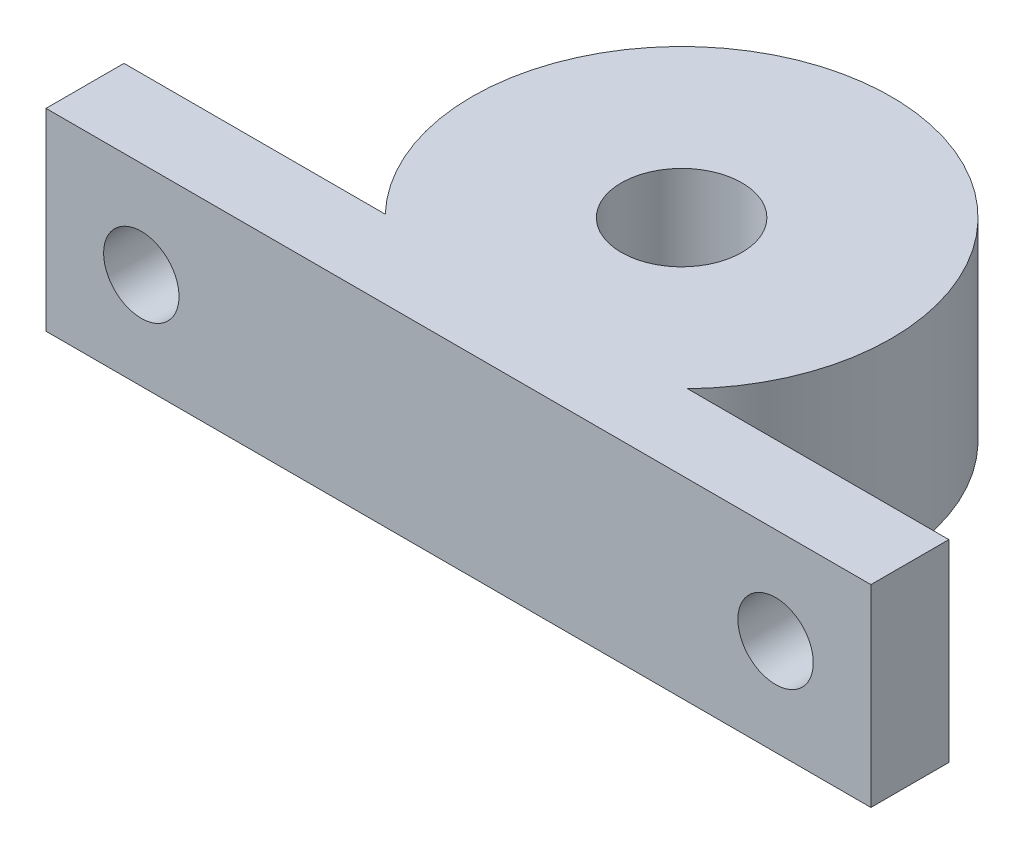
from build123d import *

# Parameters (mm, degrees)
SKETCH1_R           = 4
BOSS_EXTRUDE1_DEPTH = 12.8
SKETCH2_R           = 2.5
CUT_EXTRUDE1_DEPTH  = 6.17


with BuildPart() as part:
    # Sketch1 → Boss-Extrude1 (new body)
    with BuildSketch(Plane(origin=(0, 0, 0), x_dir=(1, 0, 0), z_dir=(0, 1, 0))):
        with BuildLine():
            Line((0, 0), (54.7, 0))
            Line((54.7, 0), (54.7, 5.17))
            Line((54.7, 5.17), (37.373627088, 5.17))
            ThreePointArc((37.373627088, 5.17), (27.35, 28.7), (17.326372912, 5.17))
            Line((17.326372912, 5.17), (0, 5.17))
            Line((0, 5.17), (0, 0))
        make_face()
        with Locations((27.35, 14.8)):
            Circle(SKETCH1_R, mode=Mode.SUBTRACT)
    extrude(amount=BOSS_EXTRUDE1_DEPTH)

    # Sketch2 → Cut-Extrude1 (cut, through all)
    with BuildSketch(Plane(origin=(0, 0, -5.17), x_dir=(-1, 0, 0), z_dir=(0, 0, -1))):
        with Locations((-48.38, 6.4)):
            Circle(SKETCH2_R)
        with Locations((-6.32, 6.4)):
            Circle(SKETCH2_R)
    extrude(amount=-CUT_EXTRUDE1_DEPTH, mode=Mode.SUBTRACT)


solid = part.part
